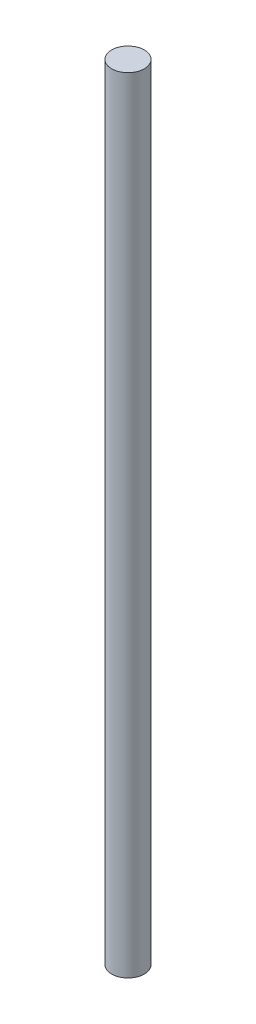
from build123d import *

# Parameters (mm, degrees)
SKETCH1_R           = 2.5
BOSS_EXTRUDE1_DEPTH = 120


with BuildPart() as part:
    # Sketch1 → Boss-Extrude1 (new body)
    with BuildSketch(Plane(origin=(0, 0, 0), x_dir=(1, 0, 0), z_dir=(0, 1, 0))):
        Circle(SKETCH1_R)
    extrude(amount=BOSS_EXTRUDE1_DEPTH)


solid = part.part
